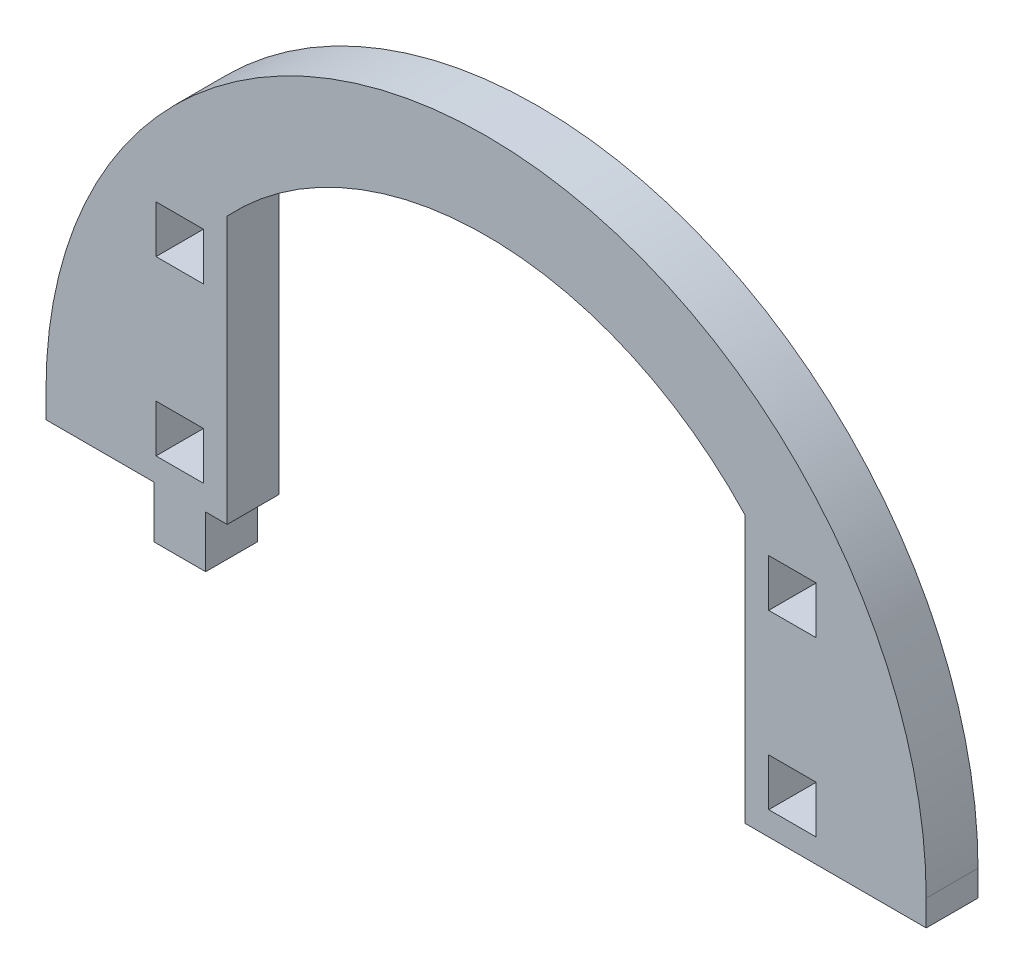
from build123d import *

# Parameters (mm, degrees)
MODEL_W             = 5.5
MODEL_H             = 5.5
BOSS_EXTRUDE1_DEPTH = 6


with BuildPart() as part:
    # Model → Boss-Extrude1 (new body)
    with BuildSketch(Plane.XY):
        with BuildLine():
            Line((3321.525540583, 1259.877349699), (3321.525540583, 1256.877349699))
            Line((3321.525540583, 1256.877349699), (3334.025540583, 1256.877349699))
            Line((3334.025540583, 1256.877349699), (3334.025540583, 1250.877349699))
            Line((3334.025540583, 1250.877349699), (3340.025540583, 1250.877349699))
            Line((3340.025540583, 1250.877349699), (3340.025540583, 1256.877349699))
            Line((3340.025540583, 1256.877349699), (3342.525540583, 1256.877349699))
            Line((3342.525540583, 1256.877349699), (3342.525540583, 1287.823726924))
            ThreePointArc((3342.525540583, 1287.823726924), (3372.525540583, 1300.877349699), (3402.525540583, 1287.823726924))
            Line((3402.525540583, 1287.823726924), (3402.525540583, 1256.877349699))
            Line((3402.525540583, 1256.877349699), (3413.525540583, 1256.877349699))
            Line((3413.525540583, 1256.877349699), (3423.525540583, 1256.877349699))
            Line((3423.525540583, 1256.877349699), (3423.525540583, 1259.877349699))
            ThreePointArc((3423.525540583, 1259.877349699), (3372.525540583, 1310.877349699), (3321.525540583, 1259.877349699))
        make_face()
        with Locations((3408.025540583, 1262.377349699)):
            Rectangle(MODEL_W, MODEL_H, mode=Mode.SUBTRACT)
        with Locations((3408.025540583, 1282.377349699)):
            Rectangle(MODEL_W, MODEL_H, mode=Mode.SUBTRACT)
        with Locations((3337.025540583, 1262.377349699)):
            Rectangle(MODEL_W, MODEL_H, mode=Mode.SUBTRACT)
        with Locations((3337.025540583, 1282.377349699)):
            Rectangle(MODEL_W, MODEL_H, mode=Mode.SUBTRACT)
    extrude(amount=BOSS_EXTRUDE1_DEPTH)


solid = part.part
